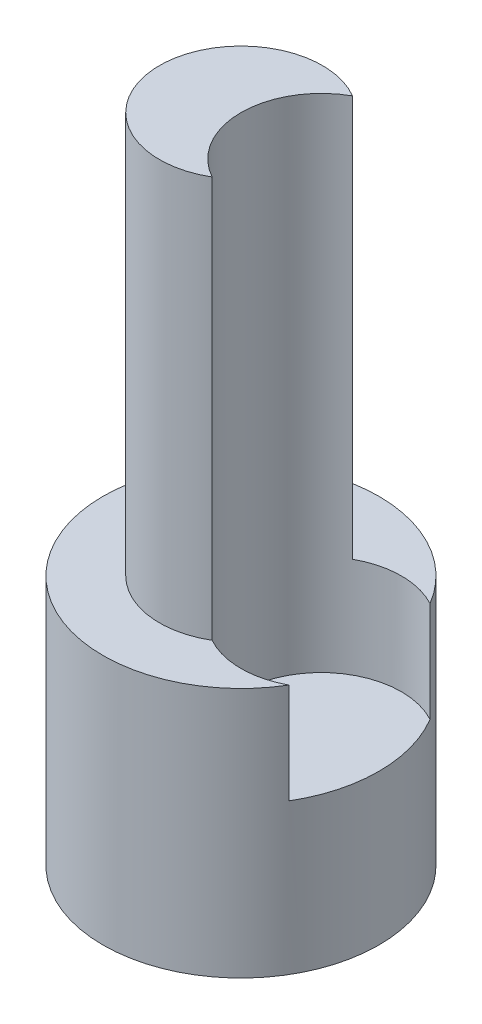
from build123d import *

# Parameters (mm, degrees)
SKETCH1_R           = 2.75
SKETCH1_R_2         = 1.625
BOSS_EXTRUDE1_DEPTH = 5
SKETCH1_4_R         = 1.625
BOSS_EXTRUDE3_DEPTH = 13
CUT_EXTRUDE3_START  = 13
SKETCH1_6_R         = 1.6
CUT_EXTRUDE3_DEPTH  = 10


with BuildPart() as part:
    # Sketch1 → Boss-Extrude1 (new body)
    with BuildSketch(Plane(origin=(0, 0, 0), x_dir=(1, 0, 0), z_dir=(0, 1, 0))):
        Circle(SKETCH1_R)
        Circle(SKETCH1_R_2, mode=Mode.SUBTRACT)
    extrude(amount=BOSS_EXTRUDE1_DEPTH)

    # Sketch1_4 → Boss-Extrude3 (add)
    with BuildSketch(Plane(origin=(0, 0, 0), x_dir=(1, 0, 0), z_dir=(0, 1, 0))):
        Circle(SKETCH1_4_R)
    extrude(amount=BOSS_EXTRUDE3_DEPTH)

    # Sketch1_6 → Cut-Extrude3 (cut)
    with BuildSketch(Plane(origin=(0, 0, 0), x_dir=(1, 0, 0), z_dir=(0, 1, 0)).offset(CUT_EXTRUDE3_START)):
        with Locations((1.6, 0)):
            Circle(SKETCH1_6_R)
    extrude(amount=-CUT_EXTRUDE3_DEPTH, mode=Mode.SUBTRACT)


solid = part.part
